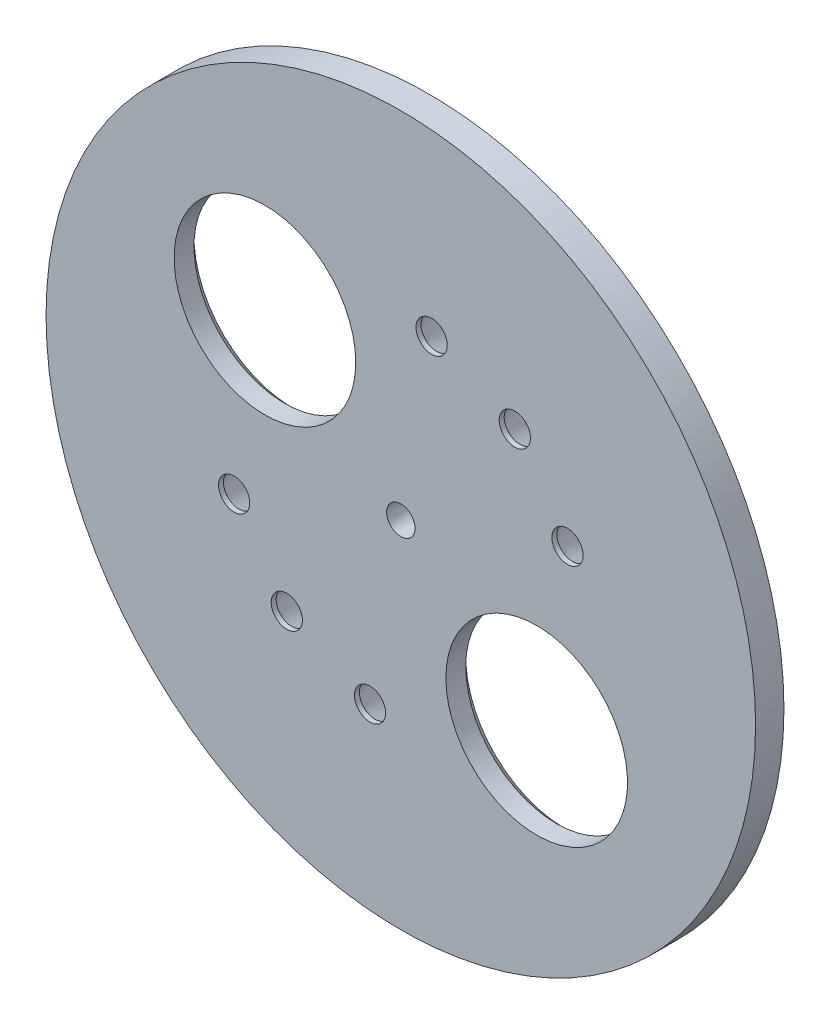
from build123d import *

# Parameters (mm, degrees)
SKETCH1_R                     = 125
BOSS_EXTRUDE1_DEPTH           = 10
SKETCH2_R                     = 5
SKETCH2_R_2                   = 32
SKETCH2_R_3                   = 5.5
CUT_EXTRUDE1_DEPTH            = 10
CHAMFER1_SIZE                 = 3
CHAMFER2_SIZE                 = 3
CHAMFER2_SIZE2                = 8.242432258
CIRPATTERN1_COUNT             = 2
CHAMFER1_OF_CIRPATTERN1_SIZE  = 3
CHAMFER2_OF_CIRPATTERN1_SIZE2 = 8.242432258
CHAMFER2_OF_CIRPATTERN1_SIZE  = 3


with BuildPart() as part:
    # Sketch1 → Boss-Extrude1 (new body)
    with BuildSketch(Plane.XY):
        Circle(SKETCH1_R)
    extrude(amount=BOSS_EXTRUDE1_DEPTH)

    # Sketch2 → Cut-Extrude1 (cut)
    with BuildSketch(Plane(origin=(0, 0, 0), x_dir=(-1, 0, 0), z_dir=(0, 0, -1))):
        Circle(SKETCH2_R)
        with Locations((-47.877777695, -40.174225605)):
            Circle(SKETCH2_R_2)
        with Locations((10.853011104, -61.550484563)):
            Circle(SKETCH2_R_3)
        with Locations((40.174225605, -47.877777695)):
            Circle(SKETCH2_R_3)
        with Locations((58.730788799, -21.376258958)):
            Circle(SKETCH2_R_3)
    cut_extrude1 = extrude(amount=-CUT_EXTRUDE1_DEPTH, mode=Mode.SUBTRACT)

    # Chamfer1
    chamfer1_edges = [part.edges().sort_by_distance(p)[0] for p in [
        (79.877777695, -40.174225605, 0),
    ]]
    chamfer(chamfer1_edges, length=CHAMFER1_SIZE)

    # Chamfer2
    chamfer2_edges = [part.edges().sort_by_distance(p)[0] for p in [
        (-53.230788799, -21.376258958, 0),
        (-34.674225605, -47.877777695, 0),
        (-5.353011104, -61.550484563, 0),
    ]]
    chamfer2_side = [part.faces().sort_by_distance(p)[0] for p in [
        (-3.873503852, 3.722299955, 0),
    ]]
    chamfer(chamfer2_edges, length=CHAMFER2_SIZE, length2=CHAMFER2_SIZE2, reference=chamfer2_side[0])

    # CirPattern1: Cut-Extrude1 ×2 about axis
    cirpattern1_axis = Axis((0, 0, 10), (0, 0, -1))
    for i in range(1, CIRPATTERN1_COUNT):
        add(cut_extrude1.rotate(cirpattern1_axis, i * 360 / CIRPATTERN1_COUNT), mode=Mode.SUBTRACT)

    # Chamfer1 of CirPattern1
    chamfer1_of_cirpattern1_edges = [part.edges().sort_by_distance(p)[0] for p in [
        (-79.877777695, 40.174225605, 0),
    ]]
    chamfer(chamfer1_of_cirpattern1_edges, length=CHAMFER1_OF_CIRPATTERN1_SIZE)

    # Chamfer2 of CirPattern1
    chamfer2_of_cirpattern1_edges = [part.edges().sort_by_distance(p)[0] for p in [
        (53.230788799, 21.376258958, 0),
        (34.674225605, 47.877777695, 0),
        (5.353011104, 61.550484563, 0),
    ]]
    chamfer(chamfer2_of_cirpattern1_edges, length=CHAMFER2_OF_CIRPATTERN1_SIZE, length2=CHAMFER2_OF_CIRPATTERN1_SIZE2)


solid = part.part
